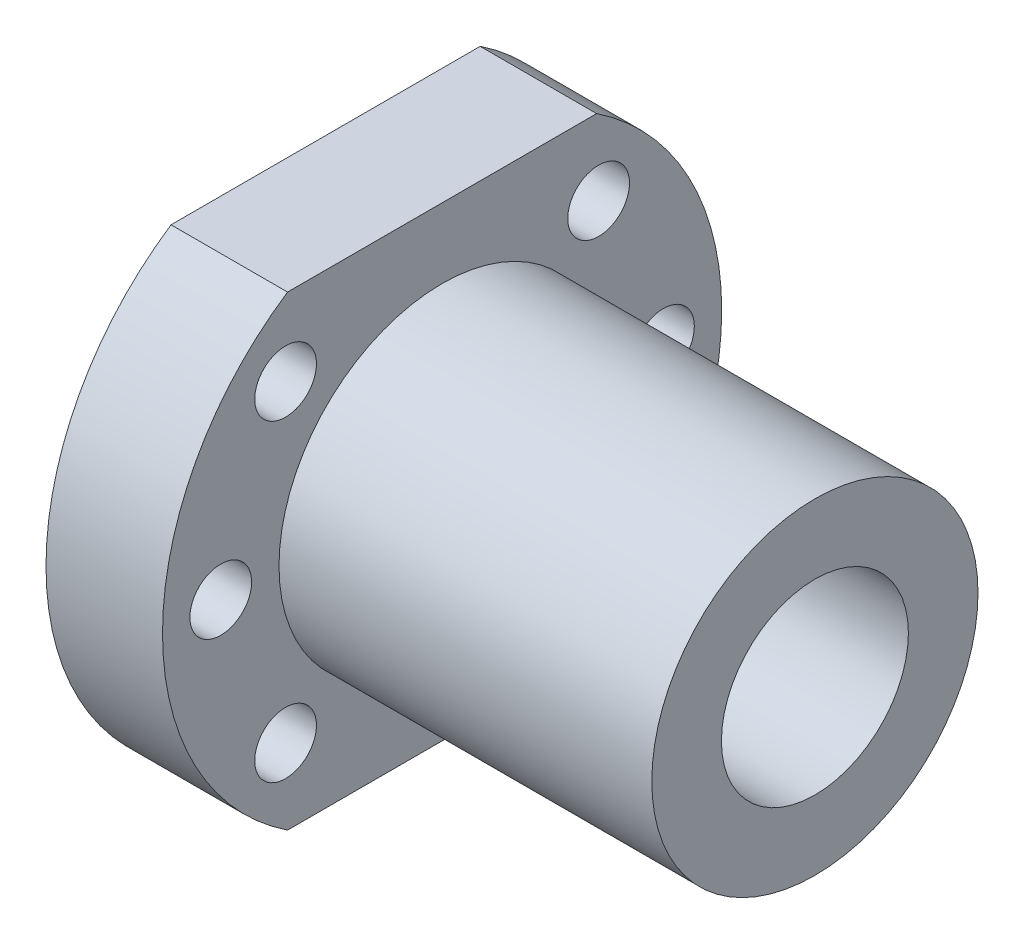
from build123d import *

# Parameters (mm, degrees)
BOSS_EXTRUDE1_DEPTH  = 10
SKETCH2_W            = 32
SKETCH2_H            = 14
HOLE1_D              = 16.05
HOLE1_DEPTH          = 42
M5_CLEARANCE_HOLE1_D = 5.3
CIRPATTERN1_COUNT    = 3
CIRPATTERN1_ANGLE    = 90
MIRROR1_COPY_1_D     = 5.3
MIRROR1_COPY_2_D     = 5.3


with BuildPart() as part:
    # Sketch1 → Boss-Extrude1 (new body)
    with BuildSketch(Plane(origin=(0, 0, 0), x_dir=(0, -1, 0), z_dir=(-1, 0, 0))):
        with BuildLine():
            Line((20, -13.266499161), (20, 13.266499161))
            ThreePointArc((20, 13.266499161), (0, 24), (-20, 13.266499161))
            Line((-20, 13.266499161), (-20, -13.266499161))
            ThreePointArc((-20, -13.266499161), (0, -24), (20, -13.266499161))
        make_face()
    extrude(amount=-BOSS_EXTRUDE1_DEPTH)

    # Sketch2 → Revolve1 (revolve)
    with BuildSketch(Plane.XY):
        with Locations((26, 7)):
            Rectangle(SKETCH2_W, SKETCH2_H)
    revolve(axis=Axis((10, 0, 0), (1, 0, 0)))

    # Hole1
    with Locations(Plane(origin=(42, 0, 0), x_dir=(0, 0, -1), z_dir=(1, 0, 0))):
        with Locations((0, 0)):
            Hole(HOLE1_D / 2, depth=HOLE1_DEPTH)

    # M5 Clearance Hole1 (through all)
    with Locations(Plane(origin=(10, 0, 0), x_dir=(0, 0, -1), z_dir=(1, 0, 0))):
        with Locations((-13.435028843, -13.435028843)):
            m5_clearance_hole1 = Hole(M5_CLEARANCE_HOLE1_D / 2)

    # CirPattern1: M5 Clearance Hole1 ×3 about axis
    cirpattern1_axis = Axis((0, 0, 0), (-1, 0, 0))
    for i in range(1, CIRPATTERN1_COUNT):
        add(m5_clearance_hole1.rotate(cirpattern1_axis, i * CIRPATTERN1_ANGLE / (CIRPATTERN1_COUNT - 1)), mode=Mode.SUBTRACT)

    # Mirror1: M5 Clearance Hole1 across plane
    add(m5_clearance_hole1.mirror(Plane.XY), mode=Mode.SUBTRACT)

    # Mirror1 copy 1 (through all)
    with Locations(Plane(origin=(10, 0, 0), x_dir=(0, -0.707106781, 0.707106781), z_dir=(1, 0, 0))):
        with Locations((-13.435028843, 13.435028843)):
            Hole(MIRROR1_COPY_1_D / 2)

    # Mirror1 copy 2 (through all)
    with Locations(Plane(origin=(10, 0, 0), x_dir=(0, -1, 0), z_dir=(1, 0, 0))):
        with Locations((-13.435028843, 13.435028843)):
            Hole(MIRROR1_COPY_2_D / 2)


solid = part.part
